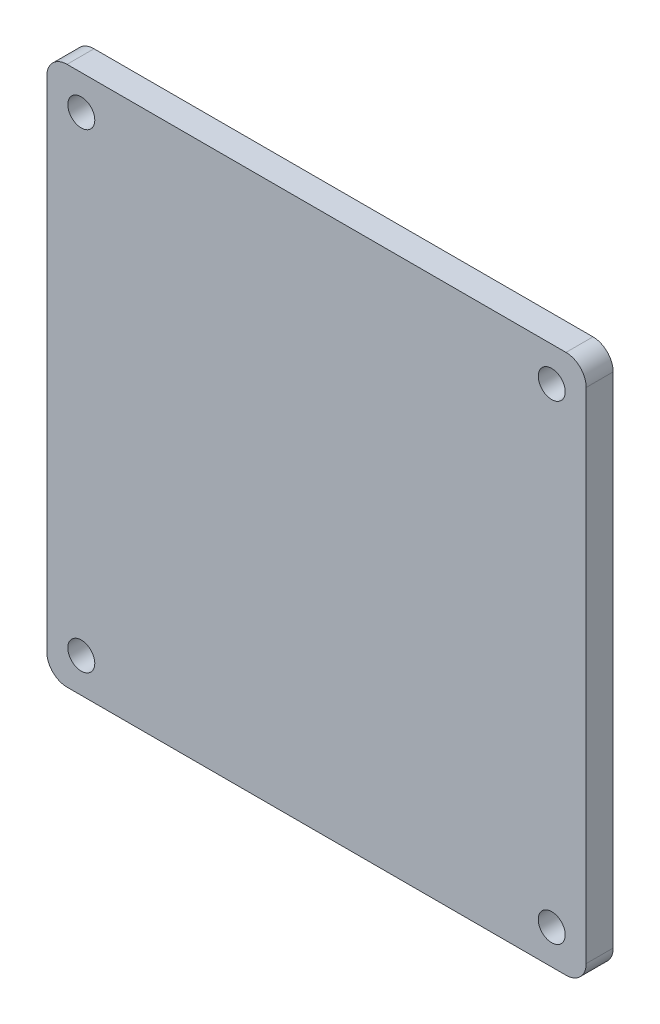
from build123d import *

# Parameters (mm, degrees)
SKETCH_1_R      = 1
EXTRUDE_1_DEPTH = 2


with BuildPart() as part:
    # 草图1 → 凸台-拉伸1 (new body)
    with BuildSketch(Plane.XY):
        with BuildLine():
            Line((-18.5, -20), (18.5, -20))
            ThreePointArc((18.5, -20), (19.560660172, -19.560660172), (20, -18.5))
            Line((20, -18.5), (20, 18.5))
            ThreePointArc((20, 18.5), (19.560660172, 19.560660172), (18.5, 20))
            Line((18.5, 20), (-18.5, 20))
            ThreePointArc((-18.5, 20), (-19.560660172, 19.560660172), (-20, 18.5))
            Line((-20, 18.5), (-20, -18.5))
            ThreePointArc((-20, -18.5), (-19.560660172, -19.560660172), (-18.5, -20))
        make_face()
        with Locations((-17.442431276, 17.442431276)):
            Circle(SKETCH_1_R, mode=Mode.SUBTRACT)
        with Locations((17.442431276, 17.442431276)):
            Circle(SKETCH_1_R, mode=Mode.SUBTRACT)
        with Locations((17.442431276, -17.442431276)):
            Circle(SKETCH_1_R, mode=Mode.SUBTRACT)
        with Locations((-17.442431276, -17.442431276)):
            Circle(SKETCH_1_R, mode=Mode.SUBTRACT)
    extrude(amount=EXTRUDE_1_DEPTH)


solid = part.part
